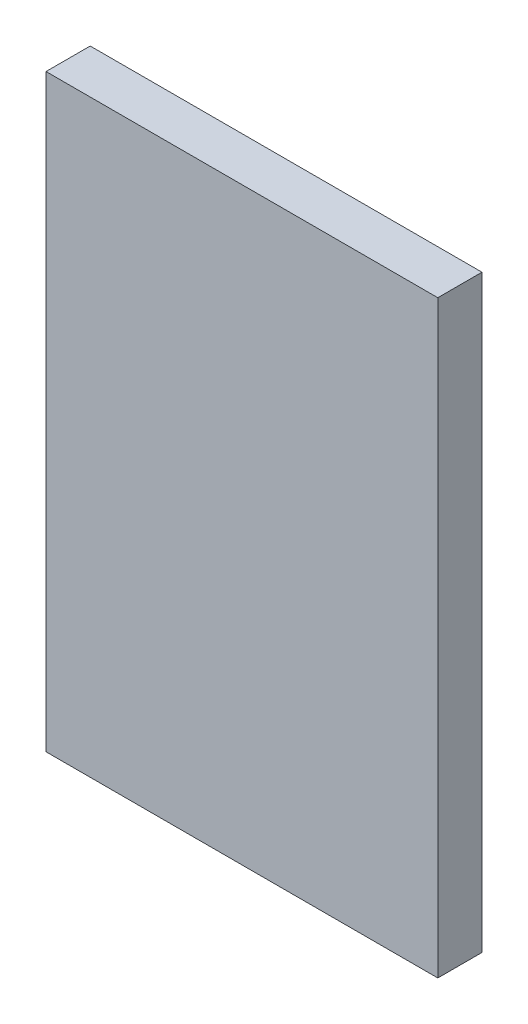
from build123d import *

# Parameters (mm, degrees)
SKETCH1_W           = 1330
SKETCH1_H           = 2000
BOSS_EXTRUDE1_DEPTH = 150


with BuildPart() as part:
    # Sketch1 → Boss-Extrude1 (new body)
    with BuildSketch(Plane.XY):
        with Locations((665, -1000)):
            Rectangle(SKETCH1_W, SKETCH1_H)
    extrude(amount=BOSS_EXTRUDE1_DEPTH)


solid = part.part
